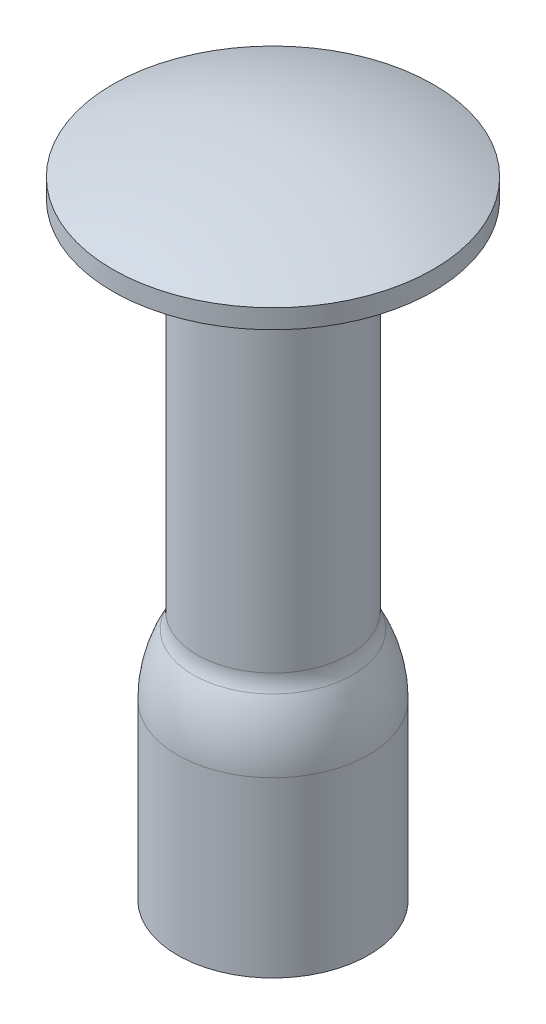
from build123d import *


with BuildPart() as part:
    # Sketch1 → Revolve1 (revolve)
    with BuildSketch(Plane.XY):
        with BuildLine():
            Line((1.3, -6.804641901), (1.3, -9.525))
            Line((1.3, -9.525), (1.5, -9.525))
            Line((1.5, -9.525), (1.5, -6.804641901))
            ThreePointArc((1.5, -6.804641901), (1.437137063, -6.307148182), (1.2525, -5.84092838))
            ThreePointArc((1.2525, -5.84092838), (1.206340734, -5.72437343), (1.190625, -5.6))
            Line((1.190625, -5.6), (1.190625, 0))
            Line((1.190625, 0), (2.5146, 0))
            Line((2.5146, 0), (2.5146, 0.3))
            ThreePointArc((2.5146, 0.3), (1.283177404, 0.68329415), (0, 0.8128))
            Line((0, 0.8128), (0, 0))
            Line((0, 0), (0.990625, 0))
            Line((0.990625, 0), (0.990625, -5.6))
            ThreePointArc((0.990625, -5.6), (1.012627028, -5.774122801), (1.07725, -5.937299732))
            ThreePointArc((1.07725, -5.937299732), (1.243423357, -6.356897554), (1.3, -6.804641901))
        make_face()
    revolve(axis=Axis((0, 0.8128, 0), (0, -1, 0)))


solid = part.part
